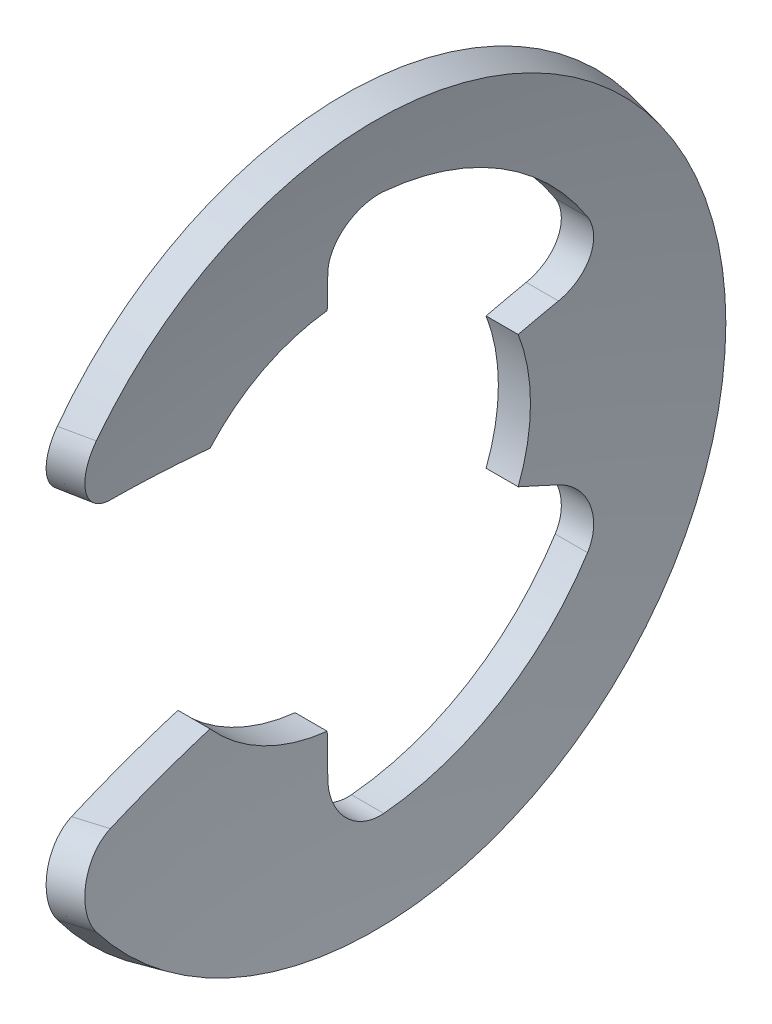
from build123d import *

# Parameters (mm, degrees)
CUT_EXTRUDE1_DEPTH = 21.30888446
FILLET1_R          = 1.778


with BuildPart() as part:
    # Sketch2 → Revolve1 (revolve)
    with BuildSketch(Plane(origin=(0, 0, 0), x_dir=(1, 0, 0), z_dir=(0, 1, 0))):
        with BuildLine():
            Line((0.283958229, 14.224), (1.524, 13.949780367))
            ThreePointArc((1.524, 13.949780367), (0.382130108, 7.016390601), (0, 0))
            Line((0, 0), (-1.27, 0))
            ThreePointArc((-1.27, 0), (-0.880358119, 7.154316218), (0.283958229, 14.224))
        make_face()
    revolve(axis=Axis((0, 0, 0), (1, 0, 0)))

    # Sketch1 → Cut-Extrude1 (cut, through all)
    with BuildSketch(Plane(origin=(1.524, 0, 0), x_dir=(0, 0, -1), z_dir=(1, 0, 0))):
        with BuildLine():
            Line((-12.820693103, -6.160519812), (-5.457008659, -4.833450169))
            ThreePointArc((-5.457008659, -4.833450169), (-3.351086736, -6.473901585), (-0.795799518, -7.246232619))
            Line((-0.795799518, -7.246232619), (-1.174289533, -10.692611547))
            ThreePointArc((-1.174289533, -10.692611547), (5.59102597, -9.189740269), (10.03567463, -3.872484))
            Line((10.03567463, -3.872484), (6.8010357, -2.624328))
            ThreePointArc((6.8010357, -2.624328), (7.2898, 0), (6.8010357, 2.624328))
            Line((6.8010357, 2.624328), (10.03567463, 3.872484))
            ThreePointArc((10.03567463, 3.872484), (5.59102597, 9.189740269), (-1.174289533, 10.692611547))
            Line((-1.174289533, 10.692611547), (-0.795799518, 7.246232619))
            ThreePointArc((-0.795799518, 7.246232619), (-3.351086736, 6.473901585), (-5.457008659, 4.833450169))
            Line((-5.457008659, 4.833450169), (-12.820693103, 6.160519812))
            ThreePointArc((-12.820693103, 6.160519812), (-14.224, 0), (-12.820693103, -6.160519812))
        make_face()
    extrude(amount=-CUT_EXTRUDE1_DEPTH, mode=Mode.SUBTRACT)

    # Fillet1
    fillet1_edges = [part.edges().sort_by_distance(p)[0] for p in [
        (0.257994341, 10.692611547, 1.174289533),
        (0.257994341, 3.872484, -10.03567463),
        (0.257994341, -3.872484, -10.03567463),
        (0.257994341, -10.692611547, 1.174289533),
        (0.9039909, 6.135280444, 12.680644128),
        (0.9039909, -6.135280444, 12.680644128),
    ]]
    fillet(fillet1_edges, radius=FILLET1_R)


solid = part.part
